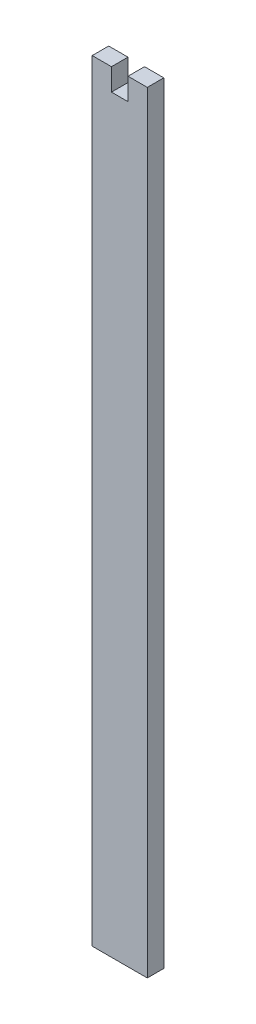
from build123d import *

# Parameters (mm, degrees)
BOSS_EXTRUDE1_DEPTH = 1.5


with BuildPart() as part:
    # Sketch1 → Boss-Extrude1 (new body, symmetric)
    with BuildSketch(Plane.XY):
        Polygon((1.5, 70), (5, 70), (5, -70), (-5, -70), (-5, 70), (-1.5, 70), (-1.5, 66), (1.5, 66), align=None)
    extrude(amount=BOSS_EXTRUDE1_DEPTH, both=True)


solid = part.part
